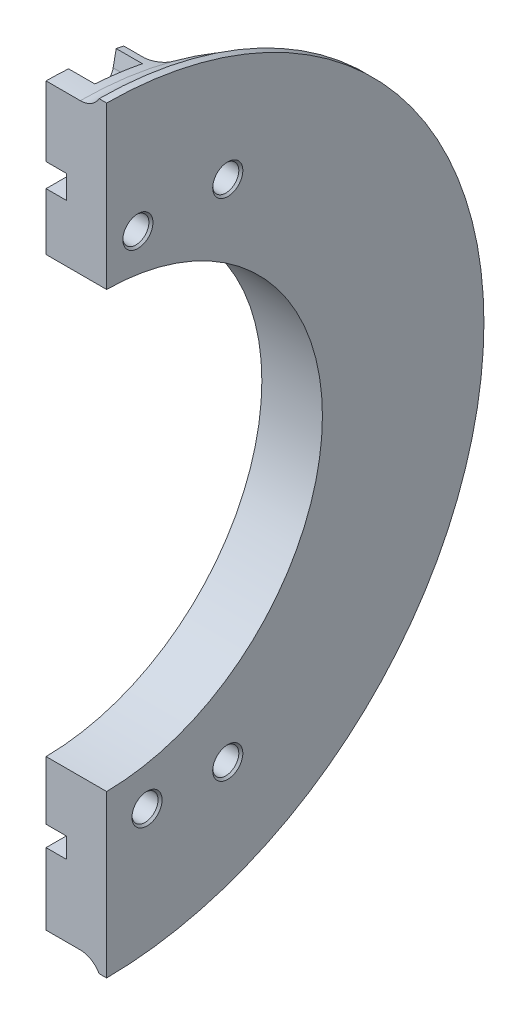
from build123d import *

# Parameters (mm, degrees)
REVOLVE_THIN1_ANGLE               = 180
SKETCH81_W                        = 41.373480097
SKETCH81_H                        = 433.466768404
EXTRUDE1_DEPTH                    = 22.75344145
EXTRUDE1_DEPTH_BACK               = 4.64655855
BOSS_EXTRUDE1_DEPTH               = 25.4
CUT_EXTRUDE1_DEPTH                = 6.35
F_5_16_CLEARANCE_HOLE1_AT_2_COUNT = 2
F_5_16_CLEARANCE_HOLE1_AT_2_PITCH = 25.4
F_5_16_CLEARANCE_HOLE1_AT_3_COUNT = 2
F_5_16_CLEARANCE_HOLE1_AT_3_PITCH = 158.75
F_5_16_CLEARANCE_HOLE1_AT_4_COUNT = 2
F_5_16_CLEARANCE_HOLE1_AT_4_PITCH = 161.247301583
CUT_EXTRUDE2_DEPTH                = 8.25
CUT_EXTRUDE3_DEPTH                = 2.5034
FILLET1_R                         = 4.7625
FILLET2_R                         = 4.7625
SKETCH88_W                        = 10
SKETCH88_H                        = 6.35254
CUT_EXTRUDE4_DEPTH                = 6.35
SKETCH89_W                        = 10
SKETCH89_H                        = 7.35254
CUT_EXTRUDE5_DEPTH                = 6.35
FILLET3_R                         = 3.175


with BuildPart() as part:
    # Sketch1 → Revolve-Thin1 (revolve)
    with BuildSketch(Plane.XY):
        with BuildLine():
            Line((21.75344145, 119.175), (13.030353167, 119.175))
            ThreePointArc((13.030353167, 119.175), (10.546995544, 116.615384298), (7.1068829, 115.675))
            Line((7.1068829, 115.675), (-3.64655855, 115.675))
            Line((-3.64655855, 115.675), (-3.64655855, 109.325))
            Line((-3.64655855, 109.325), (7.1068829, 109.325))
            ThreePointArc((7.1068829, 109.325), (11.897172557, 110.231322005), (16.025262798, 112.825))
            Line((16.025262798, 112.825), (21.75344145, 112.825))
            Line((21.75344145, 112.825), (21.75344145, 119.175))
        make_face()
    revolve(axis=Axis((0, 0, 0), (-1, 0, 0)), revolution_arc=REVOLVE_THIN1_ANGLE)

    # Sketch81 → Extrude1 (cut, two sides)
    with BuildSketch(Plane(origin=(0, 0, 0), x_dir=(0, 0, -1), z_dir=(1, 0, 0))) as extrude1_sk:
        with Locations((-20.186740049, 1.572115024)):
            Rectangle(SKETCH81_W, SKETCH81_H)
    extrude(amount=EXTRUDE1_DEPTH, mode=Mode.SUBTRACT)
    extrude(extrude1_sk.sketch, amount=-EXTRUDE1_DEPTH_BACK, mode=Mode.SUBTRACT)

    # Sketch82 → Boss-Extrude1 (add)
    with BuildSketch(Plane(origin=(21.75344145, 0, 0), x_dir=(0, 0, -1), z_dir=(1, 0, 0))):
        with BuildLine():
            Line((0.5, 112.823892084), (0.5, 68.373171822))
            ThreePointArc((0.5, 68.373171822), (68.375, 0), (0.5, -68.373171822))
            Line((0.5, -68.373171822), (0.5, -112.823892084))
            ThreePointArc((0.5, -112.823892084), (112.825, 0), (0.5, 112.823892084))
        make_face()
    extrude(amount=-BOSS_EXTRUDE1_DEPTH)

    # Sketch83 → Cut-Extrude1 (cut)
    with BuildSketch(Plane(origin=(21.75344145, 0, 0), x_dir=(0, 0, -1), z_dir=(1, 0, 0))):
        with BuildLine():
            Line((0.5, -68.373171822), (0.5, -119.173951118))
            ThreePointArc((0.5, -119.173951118), (119.175, 0), (0.5, 119.173951118))
            Line((0.5, 119.173951118), (0.5, 68.373171822))
            ThreePointArc((0.5, 68.373171822), (68.375, 0), (0.5, -68.373171822))
        make_face()
    extrude(amount=-CUT_EXTRUDE1_DEPTH, mode=Mode.SUBTRACT)

    # Sketch84 → 5_16 Clearance Hole1 (revolve, cut)
    with BuildSketch(Plane(origin=(-3.64655855, -79.375, -38.6), x_dir=(0, 0, 1), z_dir=(0, 1, 0))):
        Polygon((0, 0), (0, 19.05), (4.7371, 19.05), (4.1021, 18.415), (4.1021, 0.635), (4.7371, 0), align=None)
    f_5_16_clearance_hole1 = revolve(axis=Axis((-9.99655855, -79.375, -38.6), (1, 0, 0)), mode=Mode.SUBTRACT)

    # 5_16 Clearance Hole1 at 2: 5_16 Clearance Hole1 ×2
    with Locations(*[(0, 0, i * F_5_16_CLEARANCE_HOLE1_AT_2_PITCH) for i in range(1, F_5_16_CLEARANCE_HOLE1_AT_2_COUNT)]):
        add(f_5_16_clearance_hole1, mode=Mode.SUBTRACT)

    # 5_16 Clearance Hole1 at 3: 5_16 Clearance Hole1 ×2
    with Locations(*[(0, i * F_5_16_CLEARANCE_HOLE1_AT_3_PITCH, 0) for i in range(1, F_5_16_CLEARANCE_HOLE1_AT_3_COUNT)]):
        add(f_5_16_clearance_hole1, mode=Mode.SUBTRACT)

    # 5_16 Clearance Hole1 at 4: 5_16 Clearance Hole1 ×2
    with Locations(*[Vector(0, 0.984512599, 0.175313838) * (i * F_5_16_CLEARANCE_HOLE1_AT_4_PITCH) for i in range(1, F_5_16_CLEARANCE_HOLE1_AT_4_COUNT)]):
        add(f_5_16_clearance_hole1, mode=Mode.SUBTRACT)

    # Sketch86 → Cut-Extrude2 (cut)
    with BuildSketch(Plane.ZY.offset(3.64655855)):
        with BuildLine():
            Line((-22.551231845, 113.455487163), (-20.694300932, 104.113247999))
            ThreePointArc((-20.694300932, 104.113247999), (-13.855355304, 105.241872035), (-6.957331702, 105.921754308))
            Line((-6.957331702, 105.921754308), (-7.581623596, 115.426273476))
            ThreePointArc((-7.581623596, 115.426273476), (-15.098617285, 114.685384339), (-22.551231845, 113.455487163))
        make_face()
        with BuildLine():
            Line((-22.893664129, 103.651833765), (-24.947947227, 112.952669531))
            ThreePointArc((-24.947947227, 112.952669531), (-81.791721695, 81.797432033), (-112.95092756, 24.95583275))
            Line((-112.95092756, 24.95583275), (-103.650235233, 22.900900336))
            ThreePointArc((-103.650235233, 22.900900336), (-75.05676471, 75.062004844), (-22.893664129, 103.651833765))
        make_face()
        with BuildLine():
            Line((-113.455487163, 22.551231845), (-104.113247999, 20.694300932))
            ThreePointArc((-104.113247999, 20.694300932), (-105.241872035, 13.855355304), (-105.921754308, 6.957331702))
            Line((-105.921754308, 6.957331702), (-115.426273476, 7.581623596))
            ThreePointArc((-115.426273476, 7.581623596), (-114.685384339, 15.098617285), (-113.455487163, 22.551231845))
        make_face()
        with BuildLine():
            Line((-115.561262836, 5.128367845), (-106.045628269, 4.706083827))
            ThreePointArc((-106.045628269, 4.706083827), (-84.214457072, -64.620025689), (-22.900900336, -103.650235233))
            Line((-22.900900336, -103.650235233), (-24.95583275, -112.95092756))
            ThreePointArc((-24.95583275, -112.95092756), (-91.771147638, -70.418478301), (-115.561262836, 5.128367845))
        make_face()
        with BuildLine():
            Line((-22.551231845, -113.455487163), (-20.694300932, -104.113247999))
            ThreePointArc((-20.694300932, -104.113247999), (-13.855355304, -105.241872035), (-6.957331702, -105.921754308))
            Line((-6.957331702, -105.921754308), (-7.581623596, -115.426273476))
            ThreePointArc((-7.581623596, -115.426273476), (-15.098617285, -114.685384339), (-22.551231845, -113.455487163))
        make_face()
    extrude(amount=-CUT_EXTRUDE2_DEPTH, mode=Mode.SUBTRACT)

    # Sketch87 → Cut-Extrude3 (cut)
    with BuildSketch(Plane.ZY.offset(-4.60344145)):
        with BuildLine():
            Line((-24.95583275, -112.95092756), (-22.900900336, -103.650235233))
            ThreePointArc((-22.900900336, -103.650235233), (-84.214457072, -64.620025689), (-106.045628269, 4.706083827))
            Line((-106.045628269, 4.706083827), (-115.561262836, 5.128367845))
            ThreePointArc((-115.561262836, 5.128367845), (-91.771147638, -70.418478301), (-24.95583275, -112.95092756))
        make_face()
        with BuildLine():
            Line((-22.893664129, 103.651833765), (-24.947947227, 112.952669531))
            ThreePointArc((-24.947947227, 112.952669531), (-81.791721695, 81.797432033), (-112.95092756, 24.95583275))
            Line((-112.95092756, 24.95583275), (-103.650235233, 22.900900336))
            ThreePointArc((-103.650235233, 22.900900336), (-75.05676471, 75.062004844), (-22.893664129, 103.651833765))
        make_face()
    extrude(amount=-CUT_EXTRUDE3_DEPTH, mode=Mode.SUBTRACT)

    # Fillet1
    fillet1_edges = [part.edges().sort_by_distance(p)[0] for p in [
        (0.47844145, 105.921754308, -6.957331702),
        (0.47844145, 104.113247999, -20.694300932),
        (1.73014145, 103.651833765, -22.893664129),
        (1.73014145, 22.900900336, -103.650235233),
        (0.47844145, 20.694300932, -104.113247999),
        (0.47844145, 6.957331702, -105.921754308),
        (1.73014145, 4.706083827, -106.045628269),
        (1.73014145, -103.650235233, -22.900900336),
        (0.47844145, -104.113247999, -20.694300932),
        (0.47844145, -105.921754308, -6.957331702),
    ]]
    fillet(fillet1_edges, radius=FILLET1_R)

    # Fillet2
    fillet2_edges = [part.edges().sort_by_distance(p)[0] for p in [
        (7.10684145, -110.575810848, -24.4310649),
        (7.10684145, 24.4310649, -110.575810848),
        (7.10684145, 110.577516189, -24.423345192),
        (7.10684145, 75.062004844, -75.05676471),
        (7.10684145, 24.487736641, -104.698272262),
        (7.10684145, 104.699981573, -24.480427263),
        (7.10684145, 5.020529225, -113.131256349),
        (7.10684145, -64.620025689, -84.214457072),
        (7.10684145, -104.698272262, -24.487736641),
        (7.10684145, 3.444569602, -107.468657759),
    ]]
    fillet(fillet2_edges, radius=FILLET2_R)

    # Sketch88 → Cut-Extrude4 (cut)
    with BuildSketch(Plane.ZY.offset(3.64655855)):
        with Locations((-5.5, -90)):
            Rectangle(SKETCH88_W, SKETCH88_H)
        with Locations((-5.5, 90)):
            Rectangle(SKETCH88_W, SKETCH88_H)
    extrude(amount=-CUT_EXTRUDE4_DEPTH, mode=Mode.SUBTRACT)

    # Sketch89 → Cut-Extrude5 (cut)
    with BuildSketch(Plane.ZY.offset(3.64655855)):
        with Locations((-5.5, 90)):
            Rectangle(SKETCH89_W, SKETCH89_H)
    extrude(amount=-CUT_EXTRUDE5_DEPTH, mode=Mode.SUBTRACT)

    # Fillet3
    fillet3_edges = [part.edges().sort_by_distance(p)[0] for p in [
        (-0.47155855, -93.17627, -10.5),
        (-0.47155855, -86.82373, -10.5),
        (-0.47155855, 86.32373, -10.5),
        (-0.47155855, 93.67627, -10.5),
    ]]
    fillet(fillet3_edges, radius=FILLET3_R)


solid = part.part
